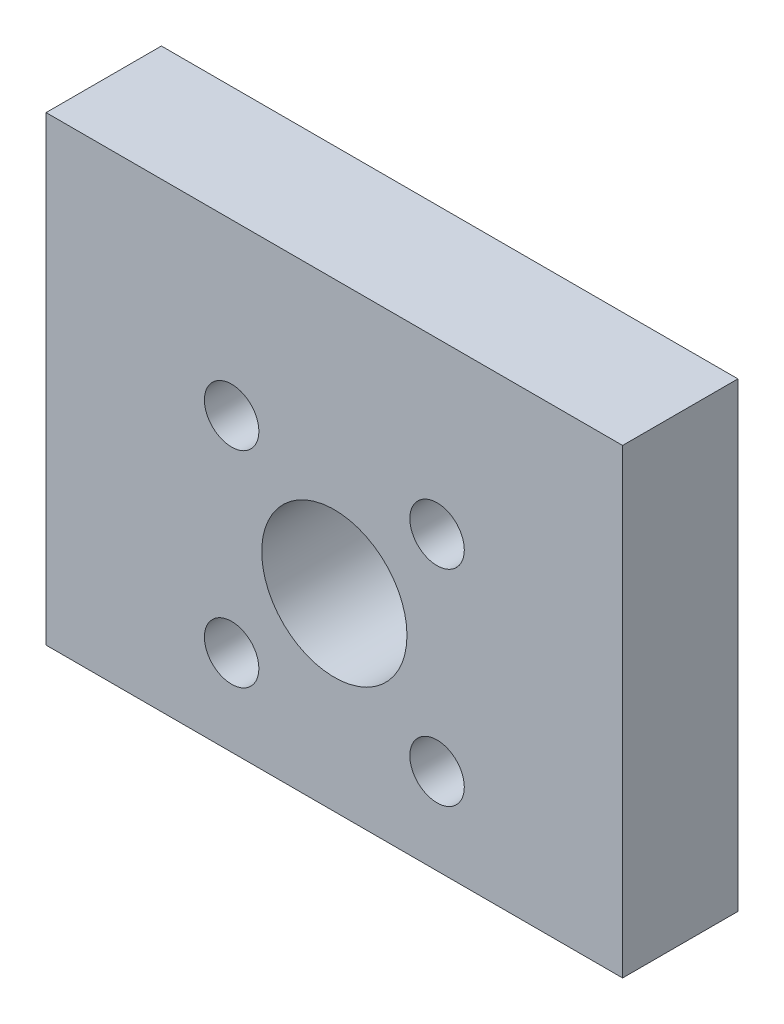
from build123d import *

# Parameters (mm, degrees)
FRONT_PROFILE_W           = 31.75
FRONT_PROFILE_H           = 25.4
FRONT_PROFILE_R           = 4
WEPON_MOTOR_MOINT_DEPTH   = 6.35
F_3_0MM_DOWEL_HOLE1_D     = 3
CIRPATTERN1_COUNT         = 4
F_3_0MM_DOWEL_HOLE2_D     = 3
F_3_0MM_DOWEL_HOLE2_DEPTH = 5
F_3_0MM_DOWEL_HOLE2_TIP   = 0.901290929


with BuildPart() as part:
    # front profile → wepon motor moint (new body)
    with BuildSketch(Plane.XY):
        with Locations((-15.875, 12.7)):
            Rectangle(FRONT_PROFILE_W, FRONT_PROFILE_H)
        with Locations((-15.875, 10.4)):
            Circle(FRONT_PROFILE_R, mode=Mode.SUBTRACT)
    extrude(amount=WEPON_MOTOR_MOINT_DEPTH)

    # Ø3.0mm Dowel Hole1 (through all)
    with Locations(Plane.XY.offset(6.35)):
        with Locations((-21.531854249, 16.056854249)):
            f_3_0mm_dowel_hole1 = Hole(F_3_0MM_DOWEL_HOLE1_D / 2)

    # CirPattern1: Ø3.0mm Dowel Hole1 ×4 about axis
    cirpattern1_axis = Axis((-15.875, 10.4, 0), (0, 0, 1))
    for i in range(1, CIRPATTERN1_COUNT):
        add(f_3_0mm_dowel_hole1.rotate(cirpattern1_axis, i * 360 / CIRPATTERN1_COUNT), mode=Mode.SUBTRACT)

    # Ø3.0mm Dowel Hole2
    with Locations(Plane(origin=(0, 0, 0), x_dir=(-1, 0, 0), z_dir=(0, -1, 0))):
        with Locations((6.35, -3.175), (25.4, -3.175)):
            Hole(F_3_0MM_DOWEL_HOLE2_D / 2, depth=F_3_0MM_DOWEL_HOLE2_DEPTH)
            with Locations((0, 0, -(F_3_0MM_DOWEL_HOLE2_DEPTH + F_3_0MM_DOWEL_HOLE2_TIP / 2))):  # 118° drill point
                Cone(0, F_3_0MM_DOWEL_HOLE2_D / 2, F_3_0MM_DOWEL_HOLE2_TIP, mode=Mode.SUBTRACT)


solid = part.part
